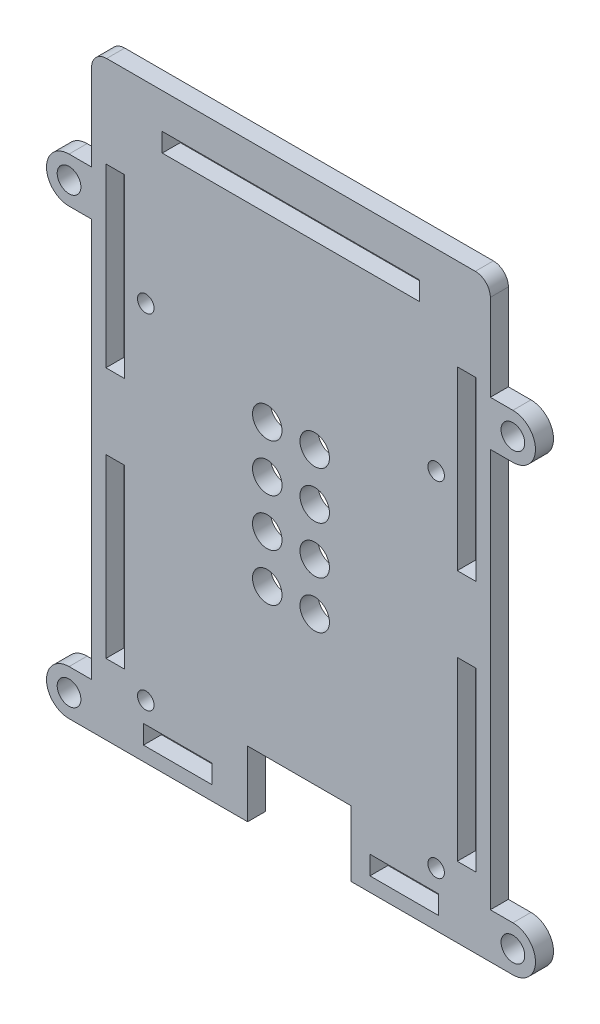
from build123d import *

# Parameters (mm, degrees)
MODEL_R             = 1.397
MODEL_W             = 11.572
MODEL_H             = 3.17
MODEL_W_2           = 3.17
MODEL_H_2           = 29.8065
MODEL_W_3           = 43.464000078
BOSS_EXTRUDE1_DEPTH = 3.048
SKETCH2_R           = 3.810000039
SKETCH2_R_2         = 2
SKETCH2_R_3         = 3.809999961
BOSS_EXTRUDE2_DEPTH = 3.048
SKETCH3_R           = 2.49
CUT_EXTRUDE1_DEPTH  = 4.048


with BuildPart() as part:
    # Model → Boss-Extrude1 (new body)
    with BuildSketch(Plane.XY):
        with BuildLine():
            Line((26.3398, 0), (2.54, 0))
            ThreePointArc((2.54, 0), (0.743948776, 0.743948776), (0, 2.54))
            Line((0, 2.54), (0, 97.154990539))
            ThreePointArc((0, 97.154990539), (0.743948776, 98.951041763), (2.54, 99.694990539))
            Line((2.54, 99.694990539), (64.77, 99.694990539))
            ThreePointArc((64.77, 99.694990539), (66.566051224, 98.951041763), (67.31, 97.154990539))
            Line((67.31, 97.154990539), (67.31, 2.54))
            ThreePointArc((67.31, 2.54), (66.566051224, 0.743948776), (64.77, 0))
            Line((64.77, 0), (43.815, 0))
            Line((43.815, 0), (43.815, 11.0744))
            Line((43.815, 11.0744), (26.3398, 11.0744))
            Line((26.3398, 11.0744), (26.3398, 0))
        make_face()
        with Locations((9.144, 9.144)):
            Circle(MODEL_R, mode=Mode.SUBTRACT)
        with Locations((58.166, 9.144)):
            Circle(MODEL_R, mode=Mode.SUBTRACT)
        with Locations((9.144, 67.183)):
            Circle(MODEL_R, mode=Mode.SUBTRACT)
        with Locations((58.166, 67.183)):
            Circle(MODEL_R, mode=Mode.SUBTRACT)
        with Locations((52.771, 3.998)):
            Rectangle(MODEL_W, MODEL_H, mode=Mode.SUBTRACT)
        with Locations((63.312, 26.82625)):
            Rectangle(MODEL_W_2, MODEL_H_2, mode=Mode.SUBTRACT)
        with Locations((63.312, 69.31275)):
            Rectangle(MODEL_W_2, MODEL_H_2, mode=Mode.SUBTRACT)
        with Locations((33.654999961, 92.141)):
            Rectangle(MODEL_W_3, MODEL_H, mode=Mode.SUBTRACT)
        with Locations((3.997999922, 69.31275)):
            Rectangle(MODEL_W_2, MODEL_H_2, mode=Mode.SUBTRACT)
        with Locations((3.997999922, 26.82625)):
            Rectangle(MODEL_W_2, MODEL_H_2, mode=Mode.SUBTRACT)
        with Locations((14.538999922, 3.998)):
            Rectangle(MODEL_W, MODEL_H, mode=Mode.SUBTRACT)
    extrude(amount=BOSS_EXTRUDE1_DEPTH)

    # Sketch2 → Boss-Extrude2 (add)
    with BuildSketch(Plane.XY.offset(3.048)):
        with BuildLine():
            Line((-3.810000039, 74.929999922), (0, 74.929999922))
            Line((0, 74.929999922), (0, 78.739999961))
            ThreePointArc((0, 78.739999961), (-1.115923175, 76.045923097), (-3.810000039, 74.929999922))
        make_face()
        with Locations((-3.810000039, 78.739999961)):
            Circle(SKETCH2_R)
        with Locations((-3.810000039, 78.739999961)):
            Circle(SKETCH2_R_2, mode=Mode.SUBTRACT)
        with BuildLine():
            ThreePointArc((-3.810000039, 82.55), (-1.115923175, 81.434076825), (0, 78.739999961))
            Line((0, 78.739999961), (0, 82.55))
            Line((0, 82.55), (-3.810000039, 82.55))
        make_face()
        with BuildLine():
            Line((67.31, 78.739999961), (67.31, 74.929999922))
            Line((67.31, 74.929999922), (71.119999961, 74.929999922))
            ThreePointArc((71.119999961, 74.929999922), (68.425923097, 76.045923097), (67.309999922, 78.739999961))
        make_face()
        with BuildLine():
            Line((67.31, 82.55), (67.31, 78.739999961))
            ThreePointArc((67.309999922, 78.739999961), (68.425923097, 81.434076825), (71.119999961, 82.55))
            Line((71.119999961, 82.55), (67.31, 82.55))
        make_face()
        with BuildLine():
            ThreePointArc((67.31, 2.54), (66.566051224, 0.743948776), (64.77, 0))
            Line((64.77, 0), (71.119999961, 0))
            ThreePointArc((71.119999961, 0), (68.425923152, 1.115923152), (67.31, 3.809999961))
            Line((67.31, 3.809999961), (67.31, 2.54))
        make_face()
        with Locations((71.119999961, 3.809999961)):
            Circle(SKETCH2_R_3)
        with Locations((71.119999961, 3.809999961)):
            Circle(SKETCH2_R_2, mode=Mode.SUBTRACT)
        with BuildLine():
            Line((67.31, 7.619999922), (67.31, 3.809999961))
            ThreePointArc((67.31, 3.809999961), (68.425923152, 6.50407677), (71.119999961, 7.619999922))
            Line((71.119999961, 7.619999922), (67.31, 7.619999922))
        make_face()
        with BuildLine():
            ThreePointArc((-7.8e-08, 3.809999961), (-1.11592323, 1.115923152), (-3.810000039, 0))
            Line((-3.810000039, 0), (2.54, 0))
            ThreePointArc((2.54, 0), (0.743948776, 0.743948776), (0, 2.54))
            Line((0, 2.54), (0, 3.809999961))
        make_face()
        with Locations((-3.810000039, 3.809999961)):
            Circle(SKETCH2_R_3)
        with Locations((-3.810000039, 3.809999961)):
            Circle(SKETCH2_R_2, mode=Mode.SUBTRACT)
        with BuildLine():
            Line((0, 7.619999922), (-3.810000039, 7.619999922))
            ThreePointArc((-3.810000039, 7.619999922), (-1.11592323, 6.50407677), (-7.8e-08, 3.809999961))
            Line((0, 3.809999961), (0, 7.619999922))
        make_face()
        with Locations((71.119999961, 78.739999961)):
            Circle(SKETCH2_R)
        with Locations((71.119999961, 78.739999961)):
            Circle(SKETCH2_R_2, mode=Mode.SUBTRACT)
    extrude(amount=-BOSS_EXTRUDE2_DEPTH)

    # Sketch3 → Cut-Extrude1 (cut, through all)
    with BuildSketch(Plane(origin=(0, 0, 0), x_dir=(-1, 0, 0), z_dir=(0, 0, -1))):
        with Locations((-29.649999961, 60.0845)):
            Circle(SKETCH3_R)
        with Locations((-37.659999961, 60.0845)):
            Circle(SKETCH3_R)
        with Locations((-37.659999961, 52.0745)):
            Circle(SKETCH3_R)
        with Locations((-29.649999961, 52.0745)):
            Circle(SKETCH3_R)
        with Locations((-29.649999961, 44.0645)):
            Circle(SKETCH3_R)
        with Locations((-37.659999961, 44.0645)):
            Circle(SKETCH3_R)
        with Locations((-29.649999961, 36.0545)):
            Circle(SKETCH3_R)
        with Locations((-37.659999961, 36.0545)):
            Circle(SKETCH3_R)
    extrude(amount=-CUT_EXTRUDE1_DEPTH, mode=Mode.SUBTRACT)


solid = part.part
